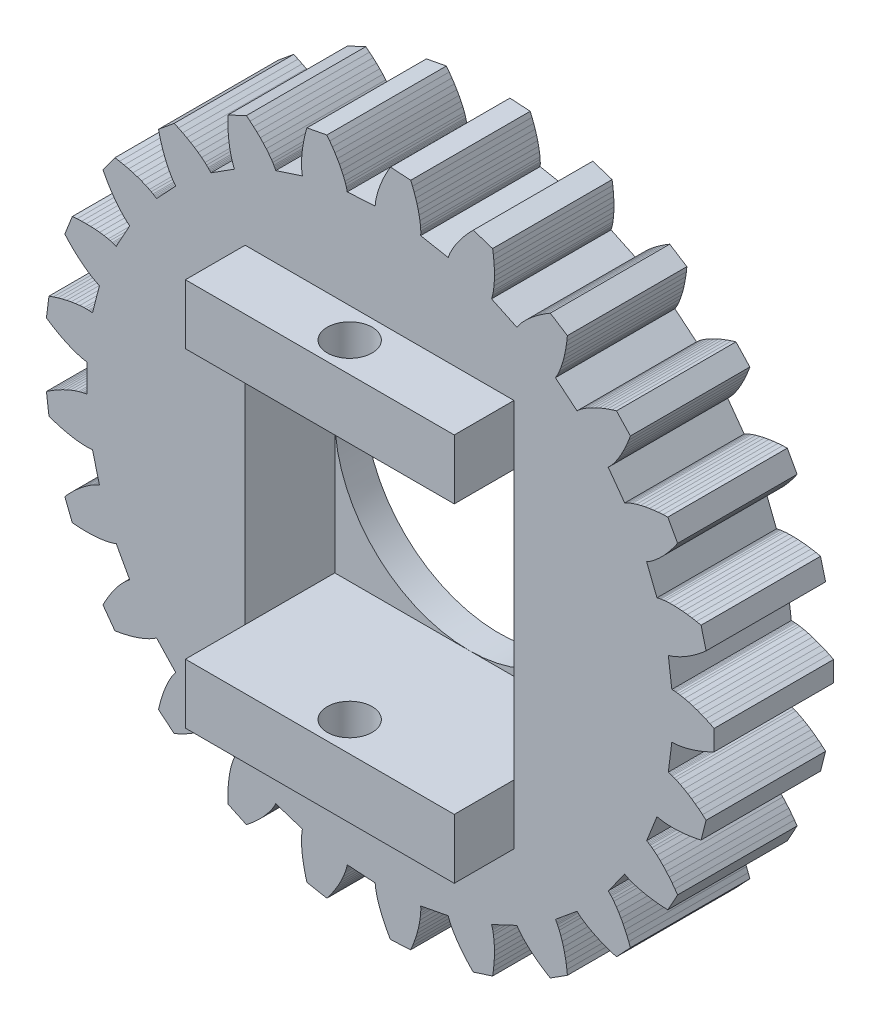
from build123d import *

# Parameters (mm, degrees)
MODEL_R             = 4.5
BOSS_EXTRUDE1_DEPTH = 4
SKETCH1_W           = 9
SKETCH1_H           = 9
CUT_EXTRUDE1_DEPTH  = 3
SKETCH2_W           = 9
SKETCH2_H           = 2
BOSS_EXTRUDE2_DEPTH = 2
SKETCH3_R           = 0.75
CUT_EXTRUDE2_DEPTH  = 18.6979296


with BuildPart() as part:
    # Model → Boss-Extrude1 (new body)
    with BuildSketch(Plane.XY):
        Polygon((22.5153116, 13.49371), (22.5501244, 13.4944492), (22.5850516, 13.4935692), (22.6200756, 13.4916244), (22.6551524, 13.4887996), (22.7254732, 13.4809588), (22.7959612, 13.4705748), (22.9373156, 13.4433212), (23.0790396, 13.4084996), (23.2209836, 13.3669196), (23.3630332, 13.319118), (23.5050916, 13.2654556), (23.6470444, 13.2062052), (23.7888124, 13.1415956), (23.93029, 13.071794), (23.93029, 12.391466), (23.7888124, 12.3216644), (23.6470444, 12.257046), (23.5050916, 12.1978044), (23.3630332, 12.144142), (23.2209836, 12.0963316), (23.0790396, 12.0547516), (22.9373156, 12.01993), (22.7959612, 11.9926764), (22.7254732, 11.9822924), (22.6551524, 11.9744516), (22.6200756, 11.9716356), (22.5850516, 11.969682), (22.5501244, 11.9688108), (22.5153116, 11.96955), (22.397462, 11.036662), (22.4313596, 11.0287244), (22.4649756, 11.0191852), (22.4984068, 11.00859), (22.5316884, 10.9971324), (22.5978468, 10.9720524), (22.6635388, 10.9444644), (22.7936732, 10.8829084), (22.9222852, 10.8139428), (23.0494276, 10.7383684), (23.1751356, 10.6567396), (23.299374, 10.569426), (23.4221428, 10.4767444), (23.5433804, 10.378906), (23.6630604, 10.2761132), (23.4938716, 9.6171516), (23.3394756, 9.5847324), (23.1860916, 9.5574084), (23.0338604, 9.5353204), (22.8829228, 9.5186708), (22.733446, 9.5076972), (22.5856236, 9.5027252), (22.4396932, 9.5042388), (22.295998, 9.5129948), (22.2251404, 9.5204748), (22.1550836, 9.5303572), (22.1204028, 9.53635), (22.0860036, 9.5431788), (22.0519476, 9.5510108), (22.0184196, 9.5603828), (21.6722716, 8.6861204), (21.7031332, 8.6699988), (21.7333172, 8.6523988), (21.76307, 8.633822), (21.7924532, 8.6144532), (21.8502868, 8.5737004), (21.9070556, 8.530642), (22.0178036, 8.4386644), (22.1252164, 8.3398756), (22.2295756, 8.2350588), (22.331022, 8.1247332), (22.4296524, 8.0092684), (22.5255108, 7.8889636), (22.6186148, 7.7640476), (22.7089732, 7.634714), (22.3812172, 7.0385404), (22.2236092, 7.0455364), (22.068254, 7.0572052), (21.91531, 7.0736788), (21.7649708, 7.0950892), (21.6174652, 7.12163), (21.4730484, 7.153574), (21.3320812, 7.1913348), (21.195074, 7.2355548), (21.1283084, 7.2604148), (21.0629068, 7.2874132), (21.0308044, 7.3018452), (20.999186, 7.3170076), (20.9681484, 7.3330676), (20.9379996, 7.3504828), (20.3853068, 6.5897668), (20.4111876, 6.566482), (20.4360564, 6.5419212), (20.4602476, 6.5165332), (20.4838844, 6.4904676), (20.5297764, 6.4366116), (20.5740492, 6.3807932), (20.6584412, 6.264158), (20.737914, 6.1417588), (20.8129252, 6.014282), (20.8837564, 5.882194), (20.950566, 5.7458292), (21.0134948, 5.6054604), (21.0726132, 5.4613164), (21.1279652, 5.313582), (20.6622428, 4.8176404), (20.5113228, 4.8636116), (20.3637556, 4.9135604), (20.2197172, 4.9675484), (20.0794276, 5.0256724), (19.9431508, 5.0880556), (19.8112124, 5.154918), (19.6840612, 5.22655), (19.562366, 5.3034532), (19.5038724, 5.3441356), (19.4472444, 5.3865516), (19.4197444, 5.4085076), (19.392878, 5.431062), (19.3668124, 5.454338), (19.3419436, 5.4787052), (18.6174308, 4.8793372), (18.6367116, 4.8503412), (18.65469, 4.8203684), (18.671806, 4.789762), (18.6882268, 4.7586364), (18.7192732, 4.6950564), (18.748278, 4.6299804), (18.8010076, 4.4960268), (18.8475508, 4.3577084), (18.888506, 4.2155796), (18.9242516, 4.0700276), (18.9550604, 3.921334), (18.9810996, 3.7697276), (19.00251, 3.6154108), (19.0193796, 3.4585508), (18.4449596, 3.0940108), (18.310214, 3.1760708), (18.1797012, 3.2611404), (18.0536148, 3.3492548), (17.9321836, 3.4404404), (17.8157068, 3.5347676), (17.7045452, 3.6323332), (17.5992092, 3.7333396), (17.5004468, 3.838086), (17.4539124, 3.8920388), (17.4096132, 3.947206), (17.3884316, 3.9753132), (17.3680332, 4.003834), (17.3485676, 4.0328564), (17.3305364, 4.0626444), (16.4797348, 3.6622884), (16.4911924, 3.6294116), (16.501154, 3.59591), (16.5101212, 3.5620124), (16.5182788, 3.5277716), (16.5325524, 3.4584716), (16.5444588, 3.38823), (16.5622172, 3.2453708), (16.5729004, 3.0998188), (16.5772212, 2.9519788), (16.575646, 2.802106), (16.5685092, 2.6504204), (16.5560308, 2.497098), (16.5383868, 2.342306), (16.515718, 2.1861764), (15.8686892, 1.9759444), (15.7585836, 2.0889364), (15.6533268, 2.203794), (15.5531124, 2.3204996), (15.458178, 2.439018), (15.368814, 2.5593404), (15.2854076, 2.6814932), (15.2084956, 2.8055204), (15.1388964, 2.9315364), (15.107234, 2.9953628), (15.0780444, 3.059814), (15.0645276, 3.0923036), (15.0518556, 3.1250044), (15.040222, 3.1579604), (15.0301724, 3.1912948), (14.1065244, 3.0151012), (14.1094548, 2.9804116), (14.110766, 2.9454844), (14.1110212, 2.9104164), (14.110414, 2.8752252), (14.1069996, 2.8045612), (14.1010596, 2.733554), (14.082738, 2.5907652), (14.0568836, 2.4471404), (14.024306, 2.3028644), (13.9855068, 2.1580868), (13.9408732, 2.0129484), (13.8906516, 1.867546), (13.8350708, 1.7220028), (13.7742892, 1.5764156), (13.0953076, 1.5337004), (13.0167588, 1.6705228), (12.9433668, 1.8079524), (12.8753252, 1.94591), (12.8128452, 2.0843076), (12.7562172, 2.2230836), (12.7058108, 2.3621324), (12.662154, 2.5013924), (12.6260828, 2.640758), (12.61129, 2.710454), (12.5990492, 2.7801412), (12.5940332, 2.8149716), (12.5898884, 2.849802), (12.5868172, 2.8846148), (12.585374, 2.9194012), (11.6469332, 2.9784404), (11.641134, 2.9441116), (11.6337244, 2.9099588), (11.62525, 2.8759292), (11.6159044, 2.8419964), (11.5950308, 2.7743948), (11.5716228, 2.7071012), (11.5183564, 2.57335), (11.4576012, 2.4406636), (11.390158, 2.3090244), (11.3165812, 2.17845), (11.2372492, 2.0489668), (11.1524524, 1.9206276), (11.0624196, 1.7934764), (10.9673444, 1.6675836), (10.2990636, 1.7950604), (10.2570084, 1.9471156), (10.22011, 2.0984756), (10.188518, 2.249026), (10.1624172, 2.3986172), (10.1420716, 2.5471084), (10.1278332, 2.6943324), (10.120186, 2.8400692), (10.1199044, 2.9840284), (10.122914, 3.0552116), (10.1283788, 3.1257524), (10.1321804, 3.1607412), (10.1368356, 3.1955012), (10.1425204, 3.2299884), (10.1497628, 3.2640444), (9.2554892, 3.5546116), (9.2413388, 3.5227996), (9.225666, 3.4915596), (9.2089988, 3.4607068), (9.1915132, 3.430162), (9.154474, 3.369882), (9.1150676, 3.3105172), (9.030218, 3.1942252), (8.9383724, 3.0808108), (8.840314, 2.9700804), (8.7365708, 2.861902), (8.62753, 2.756214), (8.513482, 2.6529988), (8.3946556, 2.55223), (8.2712532, 2.453934), (7.6556756, 2.7436036), (7.6527628, 2.9013436), (7.6546548, 3.05713), (7.6614924, 3.2108044), (7.6734164, 3.362182), (7.6906468, 3.5110692), (7.7134652, 3.6572108), (7.742294, 3.8002724), (7.7778196, 3.9397788), (7.798438, 4.0079788), (7.8212828, 4.0749468), (7.8336732, 4.1078852), (7.8468204, 4.1404012), (7.8608916, 4.1723804), (7.8763884, 4.2035676), (7.08247, 4.7074028), (7.0608484, 4.6801052), (7.0379068, 4.6537492), (7.0140852, 4.6280092), (6.9895508, 4.6027796), (6.938678, 4.5535964), (6.8857548, 4.5059004), (6.774646, 4.4143628), (6.6574828, 4.3273572), (6.5349692, 4.2444876), (6.4075804, 4.1655076), (6.275686, 4.0902588), (6.13955, 4.0186444), (5.9994012, 3.9506028), (5.8554332, 3.8860812), (5.331226, 4.3197364), (5.3676316, 4.4732436), (5.4082084, 4.623662), (5.4530444, 4.7708068), (5.5022452, 4.9144668), (5.5559604, 5.0543956), (5.6144012, 5.1902676), (5.6779108, 5.3216604), (5.7470084, 5.4479492), (5.783942, 5.5088804), (5.8227236, 5.5680604), (5.8429108, 5.5968892), (5.8637316, 5.6251108), (5.885318, 5.6525932), (5.9080836, 5.6789404), (5.2643988, 6.36439), (5.2366788, 6.3433316), (5.207894, 6.3235052), (5.1784228, 6.3044972), (5.1483884, 6.286158), (5.0868852, 6.2511692), (5.023754, 6.2181428), (4.8933732, 6.157106), (4.758258, 6.101974), (4.6189804, 6.0521748), (4.475954, 6.0073564), (4.3294868, 5.9672724), (4.1798164, 5.9317644), (4.027154, 5.9007092), (3.871658, 5.8740188), (3.4717684, 6.4244148), (3.5452044, 6.5640532), (3.6219228, 6.6996436), (3.7019412, 6.8310188), (3.7853212, 6.9579324), (3.872142, 7.0801028), (3.9625444, 7.197178), (4.0567308, 7.3086476), (4.1550708, 7.4137812), (4.2059964, 7.4636156), (4.2582684, 7.511294), (4.284994, 7.5341916), (4.3121772, 7.55635), (4.3399236, 7.577602), (4.3685236, 7.5974636), (3.9155348, 8.4214516), (3.8834412, 8.4079436), (3.8506348, 8.3959052), (3.817362, 8.384826), (3.783702, 8.37453), (3.7154316, 8.3559356), (3.6460788, 8.3396468), (3.50461, 8.3129476), (3.360026, 8.2931564), (3.2127404, 8.2795516), (3.0630612, 8.2717108), (2.9112348, 8.2693172), (2.7574372, 8.272142), (2.6018356, 8.2800268), (2.4445972, 8.2928484), (2.1941492, 8.9254012), (2.2999956, 9.0423884), (2.4080244, 9.15465), (2.5182004, 9.2619924), (2.6305236, 9.364178), (2.7450028, 9.4609252), (2.8616732, 9.5518292), (2.9806316, 9.6363796), (3.1020276, 9.713758), (3.163742, 9.7493628), (3.2262308, 9.7825388), (3.257814, 9.7980708), (3.2896524, 9.8127756), (3.3218076, 9.8264508), (3.3544468, 9.8385772), (3.1206044, 10.7493332), (3.0861612, 10.744238), (3.0513924, 10.7407356), (3.0164124, 10.7382716), (2.9812564, 10.7366788), (2.9105044, 10.7356404), (2.8392772, 10.73711), (2.6956172, 10.7464292), (2.550646, 10.7632196), (2.40461, 10.7866804), (2.2576852, 10.8163012), (2.1100212, 10.8517388), (1.9617588, 10.8927292), (1.8130124, 10.9390612), (1.6638964, 10.9905764), (1.5786332, 11.6655452), (1.7102548, 11.7525332), (1.8428004, 11.8343996), (1.9762172, 11.9109684), (2.1104172, 11.9820196), (2.2453652, 12.0472452), (2.3809732, 12.1062932), (2.5172148, 12.1586004), (2.654046, 12.2033572), (2.7226772, 12.2224884), (2.791458, 12.2390852), (2.8259012, 12.2462748), (2.8603972, 12.252602), (2.894946, 12.2578468), (2.9295828, 12.2614812), (2.9295828, 13.2017788), (2.894946, 13.2054044), (2.8603972, 13.210658), (2.8259012, 13.2169764), (2.791458, 13.224166), (2.7226772, 13.2407628), (2.654046, 13.2599028), (2.5172148, 13.3046596), (2.3809732, 13.3569668), (2.2453652, 13.416006), (2.1104172, 13.4812404), (1.9762172, 13.5522828), (1.8428004, 13.6288604), (1.7102548, 13.7107268), (1.5786332, 13.797706), (1.6638964, 14.4726748), (1.8130124, 14.5241988), (1.9617588, 14.5705308), (2.1100212, 14.6115124), (2.2576852, 14.64695), (2.40461, 14.6765796), (2.550646, 14.7000404), (2.6956172, 14.716822), (2.8392772, 14.7261412), (2.9105044, 14.7276108), (2.9812564, 14.7265812), (3.0164124, 14.7249796), (3.0513924, 14.7225244), (3.0861612, 14.7190132), (3.1206044, 14.713918), (3.3544468, 15.624674), (3.3218076, 15.6368004), (3.2896524, 15.6504844), (3.257814, 15.6651804), (3.2262308, 15.6807124), (3.163742, 15.7138972), (3.1020276, 15.7494932), (2.9806316, 15.8268716), (2.8616732, 15.911422), (2.7450028, 16.0023348), (2.6305236, 16.0990732), (2.5182004, 16.2012676), (2.4080244, 16.30861), (2.2999956, 16.4208716), (2.1941492, 16.5378588), (2.4445972, 17.1704116), (2.6018356, 17.1832244), (2.7574372, 17.1911092), (2.9112348, 17.1939428), (3.0630612, 17.1915404), (3.2127404, 17.1836996), (3.360026, 17.1701036), (3.50461, 17.1503124), (3.6460788, 17.1236132), (3.7154316, 17.1073156), (3.783702, 17.0887212), (3.817362, 17.078434), (3.8506348, 17.0673548), (3.8834412, 17.0553076), (3.9155348, 17.0418084), (4.3685236, 17.8657964), (4.3399236, 17.885658), (4.3121772, 17.9069012), (4.284994, 17.9290596), (4.2582684, 17.9519572), (4.2059964, 17.9996356), (4.1550708, 18.04947), (4.0567308, 18.1546036), (3.9625444, 18.266082), (3.872142, 18.3831484), (3.7853212, 18.5053188), (3.7019412, 18.6322324), (3.6219228, 18.7636076), (3.5452044, 18.8992068), (3.4717684, 19.0388364), (3.871658, 19.5892412), (4.027154, 19.5625508), (4.1798164, 19.5314868), (4.3294868, 19.4959788), (4.475954, 19.4559036), (4.6189804, 19.4110764), (4.758258, 19.361286), (4.8933732, 19.306154), (5.023754, 19.2451172), (5.0868852, 19.212082), (5.1483884, 19.1770932), (5.1784228, 19.158754), (5.207894, 19.1397548), (5.2366788, 19.1199284), (5.2643988, 19.09887), (5.9080836, 19.7843108), (5.885318, 19.8106668), (5.8637316, 19.8381404), (5.8429108, 19.866362), (5.8227236, 19.8951908), (5.783942, 19.9543708), (5.7470084, 20.015302), (5.6779108, 20.1415908), (5.6144012, 20.2729836), (5.5559604, 20.4088644), (5.5022452, 20.5487844), (5.4530444, 20.6924532), (5.4082084, 20.839598), (5.3676316, 20.9900076), (5.331226, 21.1435236), (5.8554332, 21.5771788), (5.9994012, 21.5126572), (6.13955, 21.4446068), (6.275686, 21.3729924), (6.4075804, 21.2977436), (6.5349692, 21.2187636), (6.6574828, 21.135894), (6.774646, 21.0488972), (6.8857548, 20.9573508), (6.938678, 20.9096548), (6.9895508, 20.8604804), (7.0140852, 20.835242), (7.0379068, 20.809502), (7.0608484, 20.783146), (7.08247, 20.7558572), (7.8763884, 21.2596924), (7.8608916, 21.2908708), (7.8468204, 21.3228588), (7.8336732, 21.355366), (7.8212828, 21.3883132), (7.798438, 21.4552724), (7.7778196, 21.5234724), (7.742294, 21.6629876), (7.7134652, 21.8060404), (7.6906468, 21.952182), (7.6734164, 22.1010692), (7.6614924, 22.2524556), (7.6546548, 22.40613), (7.6527628, 22.5619076), (7.6556756, 22.7196476), (8.2712532, 23.0093172), (8.3946556, 22.9110212), (8.513482, 22.8102612), (8.62753, 22.7070372), (8.7365708, 22.6013492), (8.840314, 22.4931708), (8.9383724, 22.3824404), (9.030218, 22.2690348), (9.1150676, 22.152734), (9.154474, 22.093378), (9.1915132, 22.0330892), (9.2089988, 22.0025532), (9.225666, 21.9716916), (9.2413388, 21.9404604), (9.2554892, 21.9086484), (10.1497628, 22.1992156), (10.1425204, 22.2332716), (10.1368356, 22.26775), (10.1321804, 22.30251), (10.1283788, 22.3374988), (10.122914, 22.4080396), (10.1199044, 22.4792228), (10.120186, 22.623182), (10.1278332, 22.7689188), (10.1420716, 22.9161428), (10.1624172, 23.064634), (10.188518, 23.214234), (10.22011, 23.3647756), (10.2570084, 23.5161356), (10.2990636, 23.6681908), (10.9673444, 23.7956764), (11.0624196, 23.6697748), (11.1524524, 23.5426324), (11.2372492, 23.4142932), (11.3165812, 23.28481), (11.390158, 23.1542268), (11.4576012, 23.0225876), (11.5183564, 22.8899012), (11.5716228, 22.7561588), (11.5950308, 22.6888652), (11.6159044, 22.6212636), (11.62525, 22.5873308), (11.6337244, 22.5533012), (11.641134, 22.5191484), (11.6469332, 22.4848108), (12.585374, 22.5438588), (12.5868172, 22.5786452), (12.5898884, 22.613458), (12.5940332, 22.6482796), (12.5990492, 22.68311), (12.61129, 22.7527972), (12.6260828, 22.8224932), (12.662154, 22.9618676), (12.7058108, 23.1011188), (12.7562172, 23.2401764), (12.8128452, 23.3789436), (12.8753252, 23.51735), (12.9433668, 23.6553076), (13.0167588, 23.7927372), (13.0953076, 23.9295596), (13.7742892, 23.8868356), (13.8350708, 23.7412484), (13.8906516, 23.5957052), (13.9408732, 23.4503116), (13.9855068, 23.3051644), (14.024306, 23.1603956), (14.0568836, 23.0161196), (14.082738, 22.872486), (14.1010596, 22.7296972), (14.1069996, 22.6586988), (14.110414, 22.588026), (14.1110212, 22.5528348), (14.110766, 22.5177668), (14.1094548, 22.4828484), (14.1065244, 22.44815), (15.0301724, 22.2719564), (15.040222, 22.3052908), (15.0518556, 22.3382468), (15.0645276, 22.3709476), (15.0780444, 22.4034372), (15.107234, 22.4678884), (15.1388964, 22.5317236), (15.2084956, 22.6577396), (15.2854076, 22.7817668), (15.368814, 22.9039108), (15.458178, 23.024242), (15.5531124, 23.1427604), (15.6533268, 23.2594572), (15.7585836, 23.3743236), (15.8686892, 23.4873068), (16.515718, 23.2770748), (16.5383868, 23.1209452), (16.5560308, 22.9661532), (16.5685092, 22.8128396), (16.575646, 22.661154), (16.5772212, 22.5112812), (16.5729004, 22.3634324), (16.5622172, 22.2178892), (16.5444588, 22.07503), (16.5325524, 22.0047796), (16.5182788, 21.9354796), (16.5101212, 21.9012476), (16.501154, 21.8673412), (16.4911924, 21.8338484), (16.4797348, 21.8009628), (17.3305364, 21.4006068), (17.3485676, 21.4303948), (17.3680332, 21.4594172), (17.3884316, 21.4879468), (17.4096132, 21.516054), (17.4539124, 21.5712212), (17.5004468, 21.625174), (17.5992092, 21.7299204), (17.7045452, 21.830918), (17.8157068, 21.9284924), (17.9321836, 22.0228108), (18.0536148, 22.1139964), (18.1797012, 22.2021108), (18.310214, 22.2871892), (18.4449596, 22.3692404), (19.0193796, 22.0047092), (19.00251, 21.8478404), (18.9810996, 21.6935236), (18.9550604, 21.541926), (18.9242516, 21.3932324), (18.888506, 21.2476716), (18.8475508, 21.1055428), (18.8010076, 20.9672332), (18.748278, 20.8332708), (18.7192732, 20.7681948), (18.6882268, 20.7046236), (18.671806, 20.6734892), (18.65469, 20.6428828), (18.6367116, 20.6129188), (18.6174308, 20.5839228), (19.3419436, 19.9845548), (19.3668124, 20.008922), (19.392878, 20.032198), (19.4197444, 20.0547436), (19.4472444, 20.0767084), (19.5038724, 20.1191244), (19.562366, 20.1598068), (19.6840612, 20.2367012), (19.8112124, 20.3083332), (19.9431508, 20.3751956), (20.0794276, 20.4375876), (20.2197172, 20.4957116), (20.3637556, 20.5496996), (20.5113228, 20.5996396), (20.6622428, 20.6456108), (21.1279652, 20.1496692), (21.0726132, 20.0019348), (21.0134948, 19.8577908), (20.950566, 19.7174308), (20.8837564, 19.581066), (20.8129252, 19.448978), (20.737914, 19.3215012), (20.6584412, 19.199102), (20.5740492, 19.0824668), (20.5297764, 19.0266484), (20.4838844, 18.9727924), (20.4602476, 18.946718), (20.4360564, 18.92133), (20.4111876, 18.896778), (20.3853068, 18.8734844), (20.9379996, 18.1127684), (20.9681484, 18.1301836), (20.999186, 18.1462436), (21.0308044, 18.161406), (21.0629068, 18.175838), (21.1283084, 18.2028452), (21.195074, 18.2277052), (21.3320812, 18.2719164), (21.4730484, 18.3096772), (21.6174652, 18.34163), (21.7649708, 18.3681708), (21.91531, 18.3895724), (22.068254, 18.406046), (22.2236092, 18.4177236), (22.3812172, 18.4247108), (22.7089732, 17.8285372), (22.6186148, 17.6992124), (22.5255108, 17.5742964), (22.4296524, 17.4539916), (22.331022, 17.3385268), (22.2295756, 17.2282012), (22.1252164, 17.1233844), (22.0178036, 17.0245956), (21.9070556, 16.9326092), (21.8502868, 16.8895508), (21.7924532, 16.8488068), (21.76307, 16.8294292), (21.7333172, 16.8108612), (21.7031332, 16.7932612), (21.6722716, 16.7771308), (22.0184196, 15.9028684), (22.0519476, 15.9122404), (22.0860036, 15.9200812), (22.1204028, 15.9269012), (22.1550836, 15.932894), (22.2251404, 15.9427852), (22.295998, 15.9502564), (22.4396932, 15.9590124), (22.5856236, 15.9605348), (22.733446, 15.9555628), (22.8829228, 15.9445804), (23.0338604, 15.9279308), (23.1860916, 15.9058516), (23.3394756, 15.8785276), (23.4938716, 15.8460996), (23.6630604, 15.1871468), (23.5433804, 15.084354), (23.4221428, 14.9865156), (23.299374, 14.8938252), (23.1751356, 14.8065204), (23.0494276, 14.7248828), (22.9222852, 14.6493172), (22.7936732, 14.5803428), (22.6635388, 14.5187868), (22.5978468, 14.4912076), (22.5316884, 14.4661188), (22.4984068, 14.4546612), (22.4649756, 14.4440748), (22.4313596, 14.4345356), (22.397462, 14.4265892), align=None)
        with Locations((12.73163, 12.73163)):
            Circle(MODEL_R, mode=Mode.SUBTRACT)
    extrude(amount=BOSS_EXTRUDE1_DEPTH)

    # Sketch1 → Cut-Extrude1 (cut)
    with BuildSketch(Plane.XY.offset(4)):
        with Locations((12.73163, 12.73163)):
            Rectangle(SKETCH1_W, SKETCH1_H)
    extrude(amount=-CUT_EXTRUDE1_DEPTH, mode=Mode.SUBTRACT)

    # Sketch2 → Boss-Extrude2 (add)
    with BuildSketch(Plane.XY.offset(4)):
        with Locations((12.73163, 7.23163)):
            Rectangle(SKETCH2_W, SKETCH2_H)
        with Locations((12.73163, 18.23163)):
            Rectangle(SKETCH2_W, SKETCH2_H)
    extrude(amount=BOSS_EXTRUDE2_DEPTH)

    # Sketch3 → Cut-Extrude2 (cut, through all)
    with BuildSketch(Plane.XZ.offset(-6.23163)):
        with Locations((12.73163, 5)):
            Circle(SKETCH3_R)
    extrude(amount=-CUT_EXTRUDE2_DEPTH, mode=Mode.SUBTRACT)


solid = part.part
